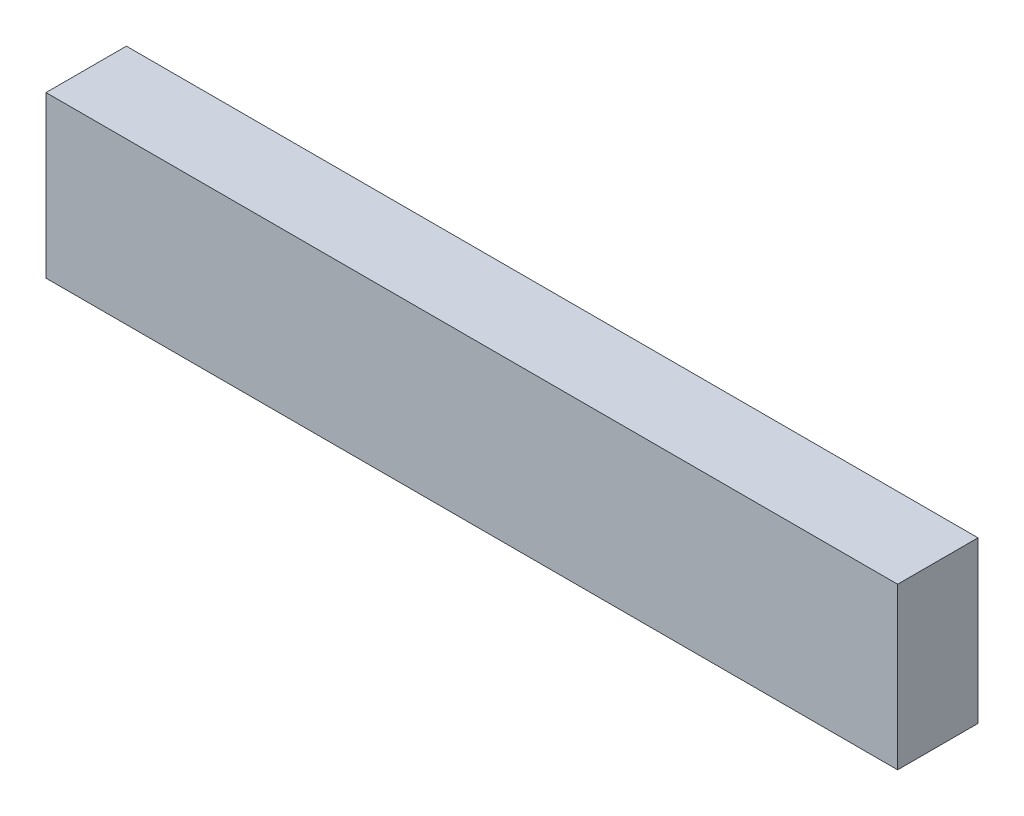
from build123d import *

# Parameters (mm, degrees)
SKETCH3_W           = 201.8284
SKETCH3_H           = 38.1
BOSS_EXTRUDE1_DEPTH = 19.05


with BuildPart() as part:
    # Sketch3 → Boss-Extrude1 (new body)
    with BuildSketch(Plane.XY):
        with Locations((75.265180392, 2.365686275)):
            Rectangle(SKETCH3_W, SKETCH3_H)
    extrude(amount=BOSS_EXTRUDE1_DEPTH)


solid = part.part
